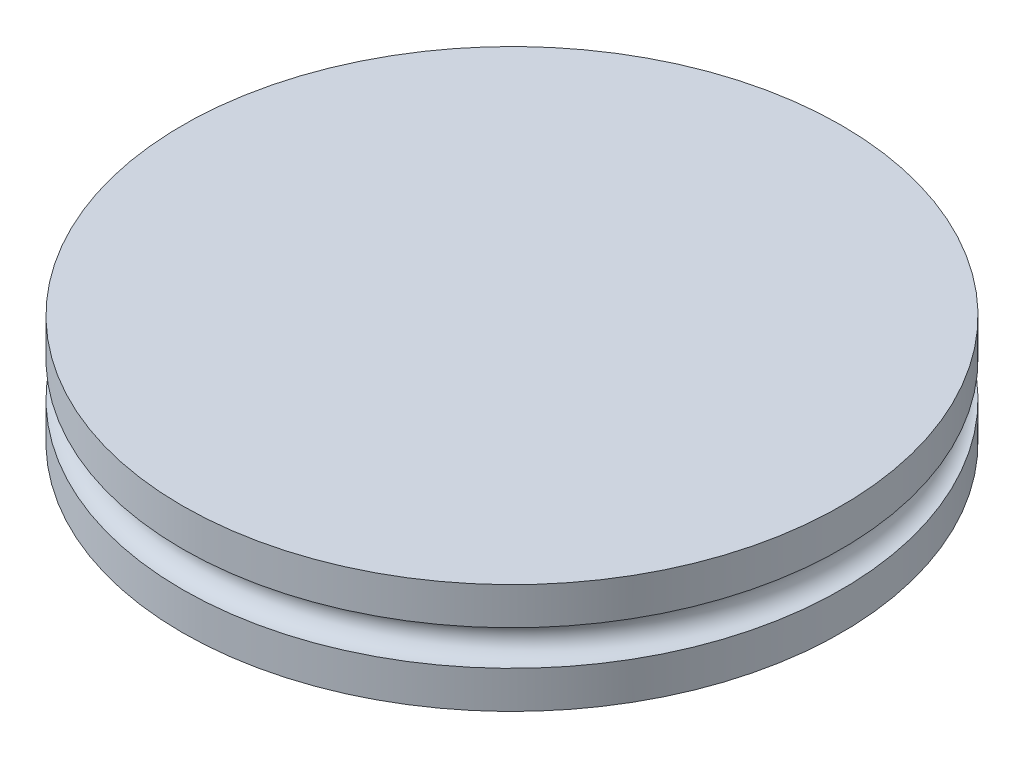
from build123d import *

# Parameters (mm, degrees)
SKETCH1_R           = 9.525
BOSS_EXTRUDE1_DEPTH = 3.175
SKETCH3_R           = 0.508
CUT_EXTRUDE1_DEPTH  = 25.4
SKETCH6_W           = 1.016
SKETCH6_H           = 1.016
CUT_EXTRUDE2_DEPTH  = 7.366
SKETCH7_W           = 1.012612731
SKETCH7_H           = 1.016
CUT_EXTRUDE3_DEPTH  = 7.366
SKETCH4_R           = 0.508


with BuildPart() as part:
    # Sketch1 → Boss-Extrude1 (new body)
    with BuildSketch(Plane(origin=(0, 0, 0), x_dir=(1, 0, 0), z_dir=(0, 1, 0))):
        Circle(SKETCH1_R)
    extrude(amount=BOSS_EXTRUDE1_DEPTH)

    # Sketch3 → Cut-Extrude1 (cut, symmetric)
    with BuildSketch(Plane.XY):
        with Locations((-8.509, 1.5875)):
            Circle(SKETCH3_R)
    extrude(amount=CUT_EXTRUDE1_DEPTH, both=True, mode=Mode.SUBTRACT)

    # Sketch6 → Cut-Extrude2 (cut)
    with BuildSketch(Plane.XY.offset(-7.62)):
        with Locations((-9.017, 1.5875)):
            Rectangle(SKETCH6_W, SKETCH6_H)
    extrude(amount=CUT_EXTRUDE2_DEPTH, mode=Mode.SUBTRACT)

    # Sketch7 → Cut-Extrude3 (cut)
    with BuildSketch(Plane.XY.offset(7.62)):
        with Locations((-9.015306366, 1.5875)):
            Rectangle(SKETCH7_W, SKETCH7_H)
    extrude(amount=-CUT_EXTRUDE3_DEPTH, mode=Mode.SUBTRACT)

    # Cut-Sweep1: sweep along a path in Sketch5
    with BuildLine(Plane(origin=(0, 0, 0), x_dir=(1, 0, 0), z_dir=(0, 1, 0))) as cut_sweep1_path:
        ThreePointArc((-7.554809844, -0.994609585), (7.62, 0), (-7.554809844, 0.994609585))
    # Sketch4 → Cut-Sweep1 (sweep, cut)
    with BuildSketch(Plane.XY):
        with Locations((9.525, 1.5875)):
            Circle(SKETCH4_R)
    sweep(path=cut_sweep1_path.line, mode=Mode.SUBTRACT)


solid = part.part
